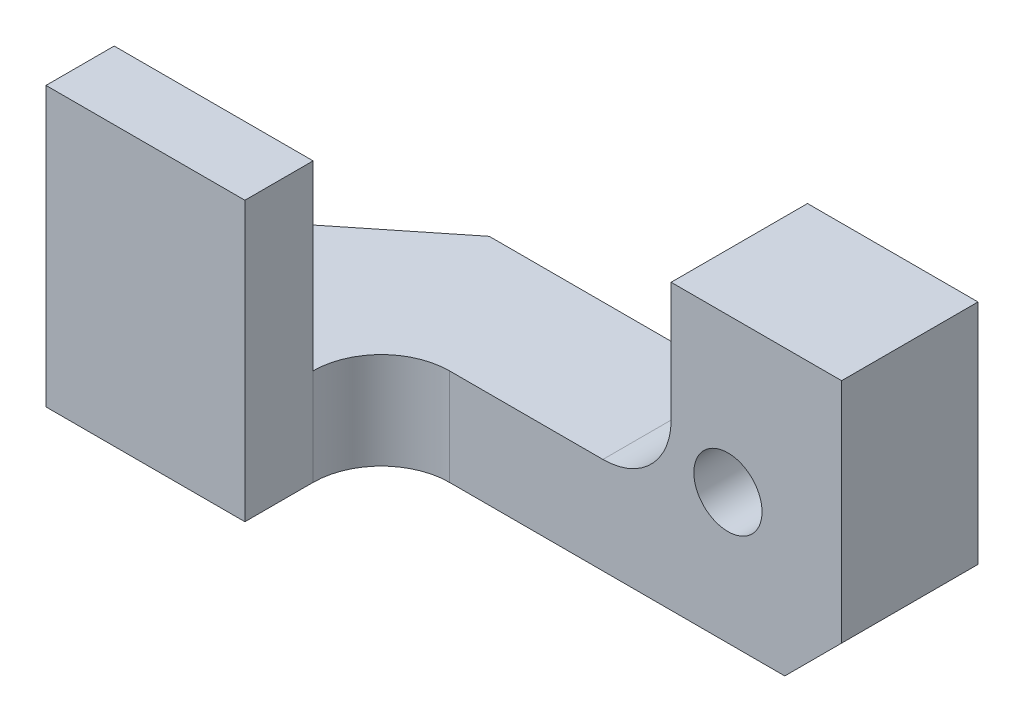
from build123d import *

# Parameters (mm, degrees)
SKETCH1_W           = 14.732
SKETCH1_H           = 6.096
BOSS_EXTRUDE1_DEPTH = 6.35
CUT_EXTRUDE2_DEPTH  = 7.35
SKETCH3_W           = 10.922
SKETCH3_H           = 6.096
CUT_EXTRUDE1_DEPTH  = 2.667
CUT_EXTRUDE3_DEPTH  = 4.683
SKETCH9_W           = 4.445
SKETCH9_H           = 1.524
BOSS_EXTRUDE2_DEPTH = 2.54
CUT_EXTRUDE4_DEPTH  = 7.096
CUT_EXTRUDE5_DEPTH  = 4.191
SKETCH15_W          = 0.048393345
SKETCH15_H          = 1.524
CUT_EXTRUDE10_DEPTH = 2.905
SKETCH13_W          = 4.445
SKETCH13_H          = 1.524
CUT_EXTRUDE11_DEPTH = 4.572
SKETCH16_R          = 0.762
CUT_EXTRUDE12_DEPTH = 4.572


with BuildPart() as part:
    # Sketch1 → Boss-Extrude1 (new body)
    with BuildSketch(Plane(origin=(0, 0, 0), x_dir=(1, 0, 0), z_dir=(0, 1, 0))):
        Rectangle(SKETCH1_W, SKETCH1_H)
    extrude(amount=BOSS_EXTRUDE1_DEPTH)

    # Sketch4 → Cut-Extrude2 (cut, through all)
    with BuildSketch(Plane(origin=(0, 6.35, 0), x_dir=(1, 0, 0), z_dir=(0, 1, 0))):
        with BuildLine():
            Line((7.366, 0), (-1.397, 0))
            ThreePointArc((-1.397, 0), (-0.319369265, -0.446369265), (0.127, -1.524))
            ThreePointArc((0.127, -1.524), (-0.319369265, -2.601630735), (-1.397, -3.048))
            Line((-1.397, -3.048), (7.366, -3.048))
            Line((7.366, -3.048), (7.366, 0))
        make_face()
        with BuildLine():
            ThreePointArc((0.127, -1.524), (-0.319369265, -0.446369265), (-1.397, 0))
            Line((-1.397, 0), (-1.397, -3.048))
            ThreePointArc((-1.397, -3.048), (-0.319369265, -2.601630735), (0.127, -1.524))
        make_face()
        with BuildLine():
            Line((-1.397, -3.048), (-1.397, 0))
            ThreePointArc((-1.397, 0), (-2.474630735, -0.446369265), (-2.921, -1.524))
            ThreePointArc((-2.921, -1.524), (-2.474630735, -2.601630735), (-1.397, -3.048))
        make_face()
        with BuildLine():
            ThreePointArc((-1.397, -3.048), (-2.474630735, -2.601630735), (-2.921, -1.524))
            Line((-2.921, -1.524), (-2.921, -3.048))
            Line((-2.921, -3.048), (-1.397, -3.048))
        make_face()
    extrude(amount=-CUT_EXTRUDE2_DEPTH, mode=Mode.SUBTRACT)

    # Sketch3 → Cut-Extrude1 (cut)
    with BuildSketch(Plane(origin=(0, 6.35, 0), x_dir=(1, 0, 0), z_dir=(0, 1, 0))):
        with Locations((-1.905, 0)):
            Rectangle(SKETCH3_W, SKETCH3_H)
    extrude(amount=-CUT_EXTRUDE1_DEPTH, mode=Mode.SUBTRACT)

    # Sketch8 → Cut-Extrude3 (cut, through all)
    with BuildSketch(Plane(origin=(0, 3.683, 0), x_dir=(1, 0, 0), z_dir=(0, 1, 0))):
        Polygon((-7.366, 0), (-3.556, 3.048), (-7.366, 3.048), align=None)
    extrude(amount=-CUT_EXTRUDE3_DEPTH, mode=Mode.SUBTRACT)

    # Sketch9 → Boss-Extrude2 (add)
    with BuildSketch(Plane(origin=(0, 3.683, 0), x_dir=(1, 0, 0), z_dir=(0, 1, 0))):
        with Locations((-5.1435, -2.286)):
            Rectangle(SKETCH9_W, SKETCH9_H)
    extrude(amount=BOSS_EXTRUDE2_DEPTH)

    # Sketch10 → Cut-Extrude4 (cut, through all)
    with BuildSketch(Plane(origin=(0, 0, -3.048), x_dir=(-1, 0, 0), z_dir=(0, 0, -1))):
        Polygon((-7.366, 1.27), (-6.096, 0), (-7.366, 0), align=None)
    extrude(amount=-CUT_EXTRUDE4_DEPTH, mode=Mode.SUBTRACT)

    # Sketch12 → Cut-Extrude5 (cut)
    with BuildSketch(Plane(origin=(0, 0, -3.048), x_dir=(-1, 0, 0), z_dir=(0, 0, -1))):
        with BuildLine():
            ThreePointArc((-3.556, 3.683), (-3.109630735, 2.605369265), (-2.032, 2.159))
            Line((-2.032, 2.159), (2.921, 2.159))
            Line((2.921, 2.159), (2.921, 3.683))
            Line((2.921, 3.683), (-3.556, 3.683))
        make_face()
    extrude(amount=-CUT_EXTRUDE5_DEPTH, mode=Mode.SUBTRACT)

    # Sketch15 → Cut-Extrude10 (cut, through all)
    with BuildSketch(Plane(origin=(0, 0, 1.143), x_dir=(-1, 0, 0), z_dir=(0, 0, -1))):
        with Locations((2.896803328, 2.921)):
            Rectangle(SKETCH15_W, SKETCH15_H)
    extrude(amount=-CUT_EXTRUDE10_DEPTH, mode=Mode.SUBTRACT)

    # Sketch13 → Cut-Extrude11 (cut)
    with BuildSketch(Plane(origin=(0, 0, -3.048), x_dir=(-1, 0, 0), z_dir=(0, 0, -1))):
        with Locations((5.1435, 2.921)):
            Rectangle(SKETCH13_W, SKETCH13_H)
    extrude(amount=-CUT_EXTRUDE11_DEPTH, mode=Mode.SUBTRACT)

    # Sketch16 → Cut-Extrude12 (cut)
    with BuildSketch(Plane(origin=(0, 0, -3.048), x_dir=(-1, 0, 0), z_dir=(0, 0, -1))):
        with Locations((-4.826, 2.921)):
            Circle(SKETCH16_R)
    extrude(amount=-CUT_EXTRUDE12_DEPTH, mode=Mode.SUBTRACT)


solid = part.part
